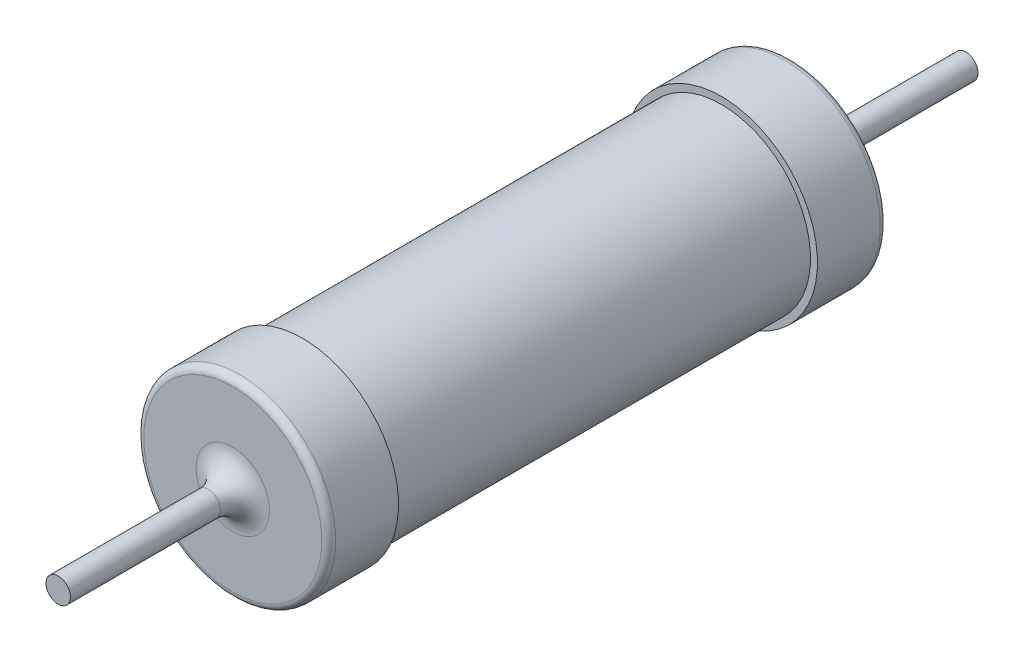
from build123d import *

# Parameters (mm, degrees)
SKETCH1_R           = 2.75
BOSS_EXTRUDE1_DEPTH = 2
SKETCH2_R           = 2.55
BOSS_EXTRUDE2_DEPTH = 12
SKETCH3_R           = 2.75
BOSS_EXTRUDE3_DEPTH = 2
SKETCH4_R           = 0.35
BOSS_EXTRUDE4_DEPTH = 5
SKETCH5_R           = 0.35
BOSS_EXTRUDE5_DEPTH = 5
FILLET1_R           = 0.2
FILLET2_R           = 0.7


with BuildPart() as part:
    # Sketch1 → Boss-Extrude1 (new body)
    with BuildSketch(Plane.XY.offset(8)):
        Circle(SKETCH1_R)
    extrude(amount=-BOSS_EXTRUDE1_DEPTH)

    # Sketch2 → Boss-Extrude2 (add)
    with BuildSketch(Plane(origin=(0, 0, 6), x_dir=(-1, 0, 0), z_dir=(0, 0, -1))):
        Circle(SKETCH2_R)
    extrude(amount=BOSS_EXTRUDE2_DEPTH)

    # Sketch3 → Boss-Extrude3 (add)
    with BuildSketch(Plane.XY.offset(-6)):
        Circle(SKETCH3_R)
    extrude(amount=-BOSS_EXTRUDE3_DEPTH)

    # Sketch4 → Boss-Extrude4 (add)
    with BuildSketch(Plane.XY.offset(8)):
        Circle(SKETCH4_R)
    extrude(amount=BOSS_EXTRUDE4_DEPTH)

    # Sketch5 → Boss-Extrude5 (add)
    with BuildSketch(Plane(origin=(0, 0, -8), x_dir=(-1, 0, 0), z_dir=(0, 0, -1))):
        Circle(SKETCH5_R)
    extrude(amount=BOSS_EXTRUDE5_DEPTH)

    # Fillet1
    fillet1_edges = [part.edges().sort_by_distance(p)[0] for p in [
        (-2.75, 0, 8),
        (-2.75, 0, -8),
    ]]
    fillet(fillet1_edges, radius=FILLET1_R)

    # Fillet2
    fillet2_edges = [part.edges().sort_by_distance(p)[0] for p in [
        (-0.35, 0, 8),
        (0.35, 0, -8),
    ]]
    fillet(fillet2_edges, radius=FILLET2_R)


solid = part.part
